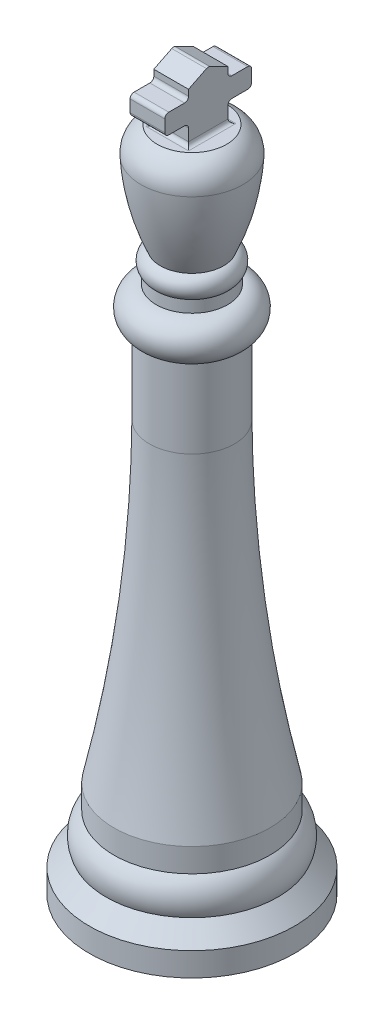
from build123d import *

# Parameters (mm, degrees)
SKETCH3_W           = 2.234278516
SKETCH3_H           = 3.869883908
BOSS_EXTRUDE1_DEPTH = 3.81
SKETCH4_W           = 2.234278516
SKETCH4_H           = 3.81
BOSS_EXTRUDE2_DEPTH = 1.27
SKETCH7_W           = 2.234278516
SKETCH7_H           = 3.81
BOSS_EXTRUDE3_DEPTH = 1.27
CUT_EXTRUDE3_DEPTH  = 2.286
FILLET1_R           = 0.254


with BuildPart() as part:
    # Sketch1 → Revolve1 (revolve)
    with BuildSketch(Plane.XY):
        with BuildLine():
            Line((0, 0), (6.604, 0))
            Line((6.604, 0), (6.604, 1.524))
            Line((6.604, 1.524), (5.526369265, 2.601630735))
            ThreePointArc((5.526369265, 2.601630735), (5.623645794, 3.729450681), (5.02050731, 4.687398762))
            Line((5.02050731, 4.687398762), (5.02050731, 6.211398762))
            add(Edge.make_bspline(
                [(5.02050731, 6.211398762), (2.796634976, 16.191993282), (2.733543957, 26.472012216)],
                knots=[0, 0, 0, 1, 1, 1], degree=2))
            Line((2.733543957, 26.472012216), (2.733543957, 31.552012216))
            ThreePointArc((2.733543957, 31.552012216), (3.551212648, 32.965759778), (2.300394609, 34.015863816))
            Line((2.300394609, 34.015863816), (2.300394609, 34.777863816))
            ThreePointArc((2.300394609, 34.777863816), (2.528411489, 35.490223347), (2.037352116, 36.054411694))
            add(Edge.make_bspline(
                [(2.037352116, 36.054411694), (2.754588802, 37.690610821), (3.171523279, 39.41712427), (3.279734912, 41.196512193)],
                knots=[0, 0, 0, 0, 0.825528863, 0.825528863, 0.825528863, 0.825528863], degree=3))
            ThreePointArc((3.279734912, 41.196512193), (3.026614336, 42.224230944), (2.234278516, 42.926))
            Line((2.234278516, 42.926), (0, 42.926))
            Line((0, 42.926), (0, 0))
        make_face()
    revolve(axis=Axis((0, 0, 0), (0, 1, 0)))

    # Sketch3 → Boss-Extrude1 (add)
    with BuildSketch(Plane(origin=(0, 42.926, 0), x_dir=(1, 0, 0), z_dir=(0, 1, 0))):
        Rectangle(SKETCH3_W, SKETCH3_H)
    extrude(amount=BOSS_EXTRUDE1_DEPTH)

    # Sketch4 → Boss-Extrude2 (add)
    with BuildSketch(Plane(origin=(0, 0, -1.934941954), x_dir=(-1, 0, 0), z_dir=(0, 0, -1))):
        with Locations((0, 44.831)):
            Rectangle(SKETCH4_W, SKETCH4_H)
    extrude(amount=BOSS_EXTRUDE2_DEPTH)

    # Sketch7 → Boss-Extrude3 (add)
    with BuildSketch(Plane.XY.offset(1.934941954)):
        with Locations((0, 44.831)):
            Rectangle(SKETCH7_W, SKETCH7_H)
    extrude(amount=BOSS_EXTRUDE3_DEPTH)

    # Sketch11 → Cut-Extrude3 (cut)
    with BuildSketch(Plane(origin=(1.117139258, 0, 0), x_dir=(0, 0, -1), z_dir=(1, 0, 0))):
        with BuildLine():
            Line((-1.934941954, 42.926), (-1.33813329, 42.926))
            Line((-1.33813329, 42.926), (-1.33813329, 43.942))
            ThreePointArc((-1.33813329, 43.942), (-1.412528167, 44.121605122), (-1.59213329, 44.196))
            Line((-1.59213329, 44.196), (-2.60813329, 44.196))
            ThreePointArc((-2.60813329, 44.196), (-2.787738412, 44.270394878), (-2.86213329, 44.45))
            Line((-2.86213329, 44.45), (-2.86213329, 45.212))
            ThreePointArc((-2.86213329, 45.212), (-2.787738412, 45.391605122), (-2.60813329, 45.466))
            Line((-2.60813329, 45.466), (-1.59213329, 45.466))
            ThreePointArc((-1.59213329, 45.466), (-1.412528167, 45.540394878), (-1.33813329, 45.72))
            Line((-1.33813329, 45.72), (-1.33813329, 46.10618983))
            Line((-1.33813329, 46.10618983), (-0.180981014, 46.680037288))
            ThreePointArc((-0.180981014, 46.680037288), (-0.06813329, 46.706482039), (0.044714435, 46.680037288))
            Line((0.044714435, 46.680037288), (1.20186671, 46.10618983))
            Line((1.20186671, 46.10618983), (1.20186671, 45.72))
            ThreePointArc((1.20186671, 45.72), (1.276261588, 45.540394878), (1.45586671, 45.466))
            Line((1.45586671, 45.466), (2.47186671, 45.466))
            ThreePointArc((2.47186671, 45.466), (2.651471833, 45.391605122), (2.72586671, 45.212))
            Line((2.72586671, 45.212), (2.72586671, 44.45))
            ThreePointArc((2.72586671, 44.45), (2.651471833, 44.270394878), (2.47186671, 44.196))
            Line((2.47186671, 44.196), (1.45586671, 44.196))
            ThreePointArc((1.45586671, 44.196), (1.276261588, 44.121605122), (1.20186671, 43.942))
            Line((1.20186671, 43.942), (1.20186671, 42.926))
            Line((1.20186671, 42.926), (1.934941954, 42.926))
            Line((1.934941954, 42.926), (3.204941954, 42.926))
            Line((3.204941954, 42.926), (3.204941954, 46.736))
            Line((3.204941954, 46.736), (-3.204941954, 46.736))
            Line((-3.204941954, 46.736), (-3.204941954, 42.926))
            Line((-3.204941954, 42.926), (-1.934941954, 42.926))
        make_face()
    extrude(amount=-CUT_EXTRUDE3_DEPTH, mode=Mode.SUBTRACT)

    # Fillet1
    fillet1_edges = [part.edges().sort_by_distance(p)[0] for p in [
        (0, 42.926, 1.33813329),
        (-1.117139258, 42.926, 0.06813329),
        (1.117139258, 42.926, 0.06813329),
        (0, 42.926, -1.20186671),
    ]]
    fillet(fillet1_edges, radius=FILLET1_R)


solid = part.part
